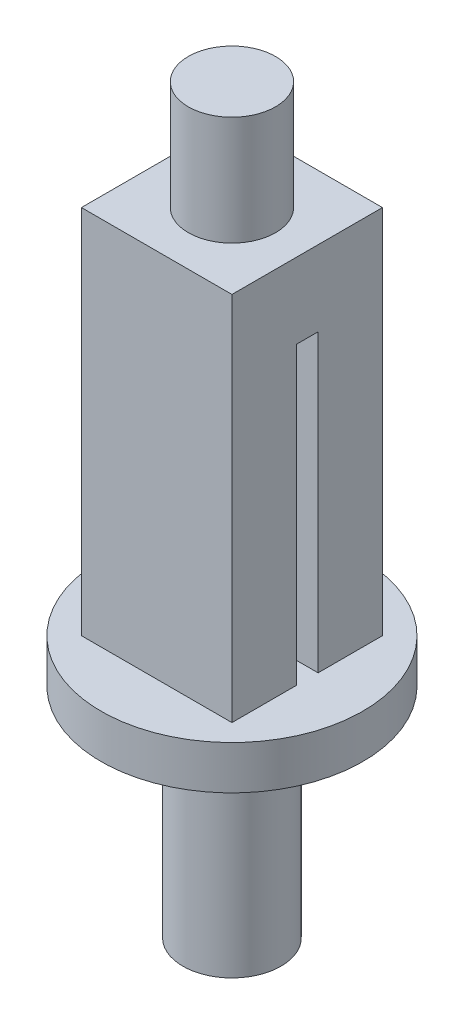
from build123d import *

# Parameters (mm, degrees)
SKETCH_2_W          = 6.9
SKETCH_2_H          = 6.9
EXTRUDE_1_DEPTH     = 17
SKETCH_3_R          = 2
EXTRUDE_2_DEPTH     = 5
SKETCH_4_W          = 1
SKETCH_4_H          = 13.542540749
CUT_EXTRUDE_1_DEPTH = 15
SKETCH_5_R          = 6
EXTRUDE_3_DEPTH     = 2
SKETCH_6_R          = 2.25
EXTRUDE_4_DEPTH     = 10
SKETCH_7_R          = 1.5
CUT_EXTRUDE_2_DEPTH = 25.542541


with BuildPart() as part:
    # 草图2 → 凸台-拉伸1 (new body)
    with BuildSketch(Plane(origin=(0, 0, 0), x_dir=(1, 0, 0), z_dir=(0, 1, 0))):
        with Locations((-0.118382353, 0.625735294)):
            Rectangle(SKETCH_2_W, SKETCH_2_H)
    extrude(amount=EXTRUDE_1_DEPTH)

    # 草图3 → 凸台-拉伸2 (add)
    with BuildSketch(Plane(origin=(0, 17, 0), x_dir=(1, 0, 0), z_dir=(0, 1, 0))):
        with Locations((-0.118382353, 0.625735294)):
            Circle(SKETCH_3_R)
    extrude(amount=EXTRUDE_2_DEPTH)

    # 草图4 → 切除-拉伸1 (cut)
    with BuildSketch(Plane.ZY.offset(3.568382353)):
        with Locations((-0.625735294, 6.771270375)):
            Rectangle(SKETCH_4_W, SKETCH_4_H)
    extrude(amount=-CUT_EXTRUDE_1_DEPTH, mode=Mode.SUBTRACT)

    # 草图5 → 凸台-拉伸3 (add)
    with BuildSketch(Plane.XZ):
        with Locations((-0.118382353, -0.625735294)):
            Circle(SKETCH_5_R)
    extrude(amount=EXTRUDE_3_DEPTH)

    # 草图6 → 凸台-拉伸4 (add)
    with BuildSketch(Plane.XZ.offset(2)):
        with Locations((-0.118382353, -0.625735294)):
            Circle(SKETCH_6_R)
    extrude(amount=EXTRUDE_4_DEPTH)

    # 草图7 → 切除-拉伸2 (cut)
    with BuildSketch(Plane.XZ.offset(12)):
        with Locations((-0.118382353, -0.625735294)):
            Circle(SKETCH_7_R)
    extrude(amount=-CUT_EXTRUDE_2_DEPTH, mode=Mode.SUBTRACT)


solid = part.part
